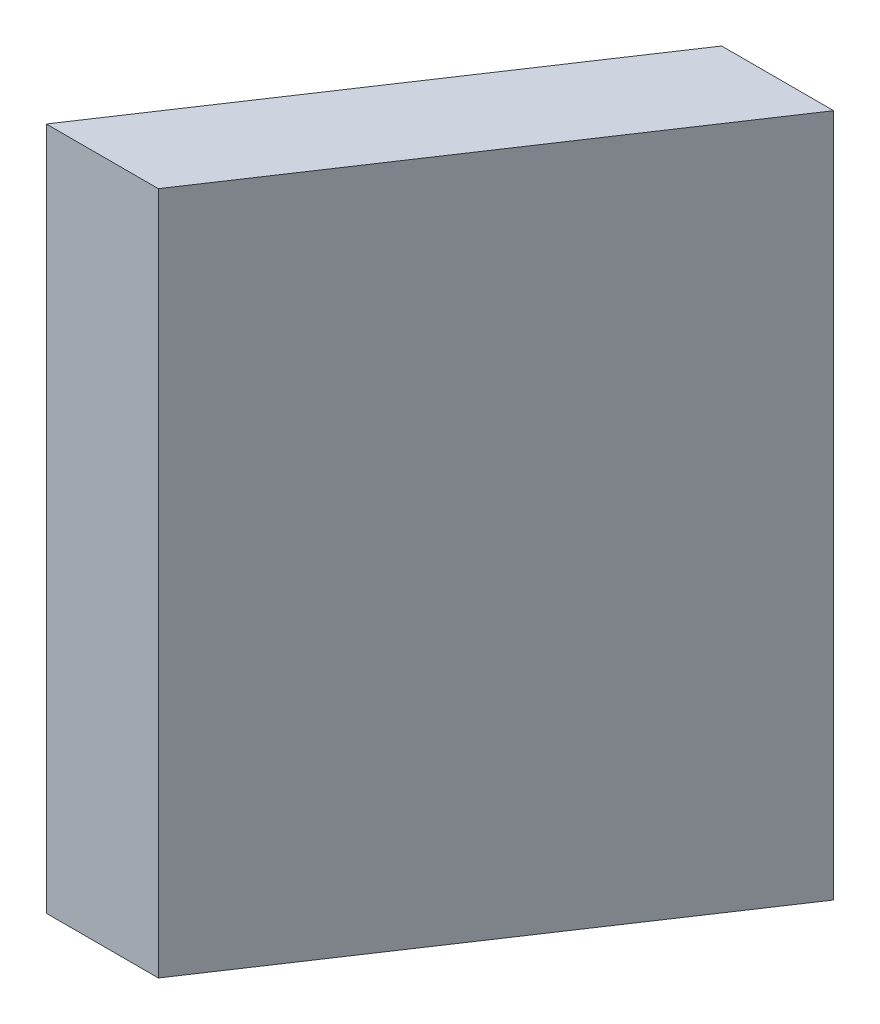
from build123d import *

# Parameters (mm, degrees)
BOSS_EXTRUDE1_DEPTH = 69.85


with BuildPart() as part:
    # Sketch1 → Boss-Extrude1 (new body)
    with BuildSketch(Plane(origin=(0, 0, 0), x_dir=(1, 0, 0), z_dir=(0, 1, 0))):
        Polygon((39.04895885, 41.402), (11.447625324, 0), (0, 0), (27.601333526, 41.402), align=None)
    extrude(amount=BOSS_EXTRUDE1_DEPTH)


solid = part.part
